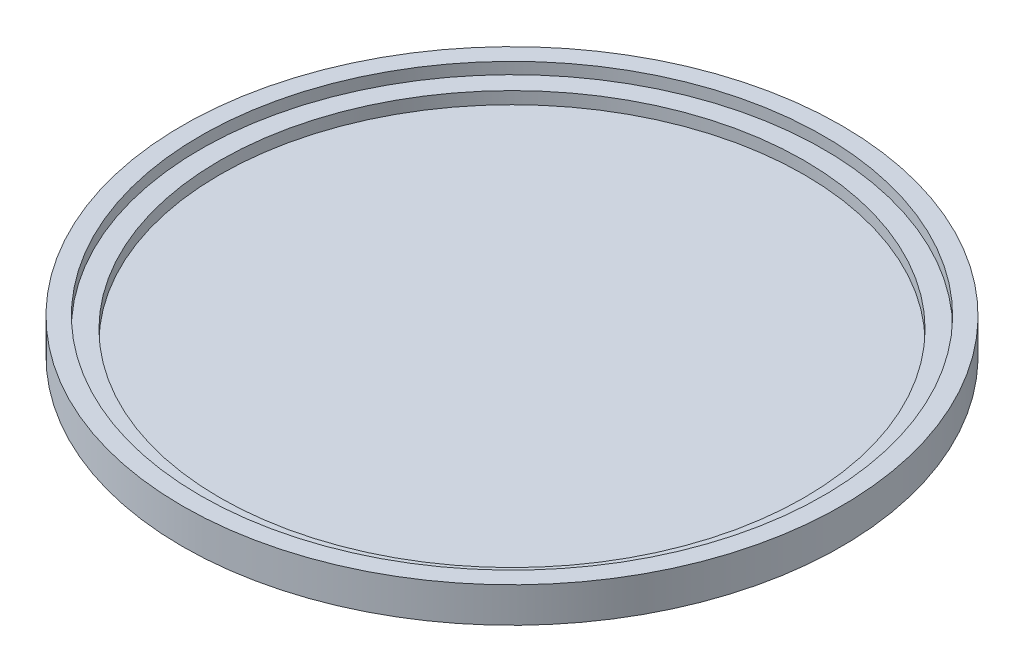
from build123d import *

# Parameters (mm, degrees)
ESBO_O1_R                = 154
RESSALTO_EXTRUS_O1_DEPTH = 16.4
ESBO_O2_R                = 145.6
CORTE_EXTRUS_O1_DEPTH    = 5.4
ESBO_O3_R                = 136.5
CORTE_EXTRUS_O2_DEPTH    = 5.72
ESBO_O4_R                = 152.8
CORTE_EXTRUS_O5_DEPTH    = 4.08


with BuildPart() as part:
    # Esboço1 → Ressalto-extrusão1 (new body)
    with BuildSketch(Plane(origin=(0, 0, 0), x_dir=(1, 0, 0), z_dir=(0, 1, 0))):
        Circle(ESBO_O1_R)
    extrude(amount=RESSALTO_EXTRUS_O1_DEPTH)

    # Esboço2 → Corte-extrusão1 (cut)
    with BuildSketch(Plane(origin=(0, 16.4, 0), x_dir=(1, 0, 0), z_dir=(0, 1, 0))):
        Circle(ESBO_O2_R)
    extrude(amount=-CORTE_EXTRUS_O1_DEPTH, mode=Mode.SUBTRACT)

    # Esboço3 → Corte-extrusão2 (cut)
    with BuildSketch(Plane(origin=(0, 11, 0), x_dir=(1, 0, 0), z_dir=(0, 1, 0))):
        Circle(ESBO_O3_R)
    extrude(amount=-CORTE_EXTRUS_O2_DEPTH, mode=Mode.SUBTRACT)

    # Esboço4 → Corte-extrusão5 (cut)
    with BuildSketch(Plane.XZ):
        Circle(ESBO_O4_R)
    extrude(amount=-CORTE_EXTRUS_O5_DEPTH, mode=Mode.SUBTRACT)


solid = part.part
